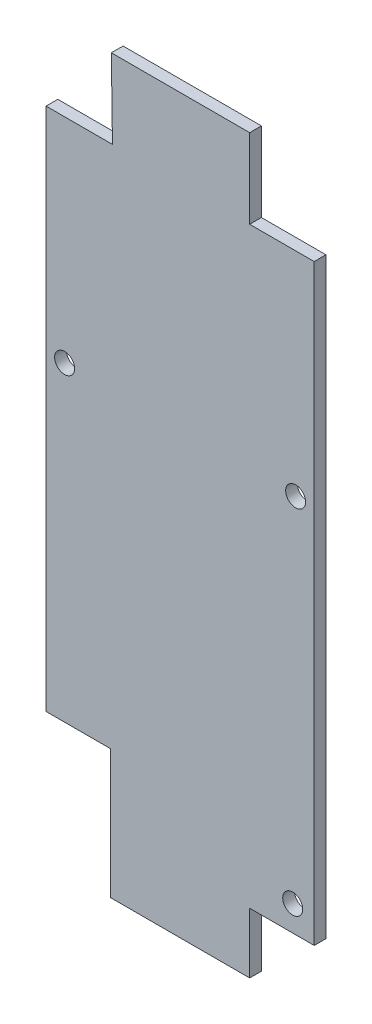
from build123d import *

# Parameters (mm, degrees)
BOSS_EXTRUDE1_DEPTH   = 1.5875
SKETCH2_W             = 8.73125
SKETCH2_H             = 9.2837
BOSS_EXTRUDE2_DEPTH   = 1.5875
F_2_CLEARANCE_HOLE1_D = 2.7051


with BuildPart() as part:
    # Sketch1 → Boss-Extrude1 (new body)
    with BuildSketch(Plane.XY):
        Polygon((-30.8483, -49.68875), (-30.8483, -98.31705), (-22.11705, -98.31705), (-22.11705, -115.77955), (-3.28295, -115.77955), (-3.28295, -98.31705), (5.4483, -98.31705), (5.4483, -49.68875), (5.4483, -27.41295), (-3.28295, -27.41295), (-3.28295, -16.66875), (-22.014883705, -16.66875), (-21.862168628, -27.33675), (-30.8483, -27.33675), align=None)
    extrude(amount=BOSS_EXTRUDE1_DEPTH)

    # Sketch2 → Boss-Extrude2 (add, through all)
    with BuildSketch(Plane.XY.offset(1.5875)):
        with Locations((1.082675, -102.9589)):
            Rectangle(SKETCH2_W, SKETCH2_H)
    extrude(amount=-BOSS_EXTRUDE2_DEPTH)

    # #2 Clearance Hole1 (through all)
    with Locations(Plane.XY.offset(1.5875)):
        with Locations((2.54, -104.14), (-28.336875, -56.1975), (2.936875, -56.1975)):
            Hole(F_2_CLEARANCE_HOLE1_D / 2)


solid = part.part
